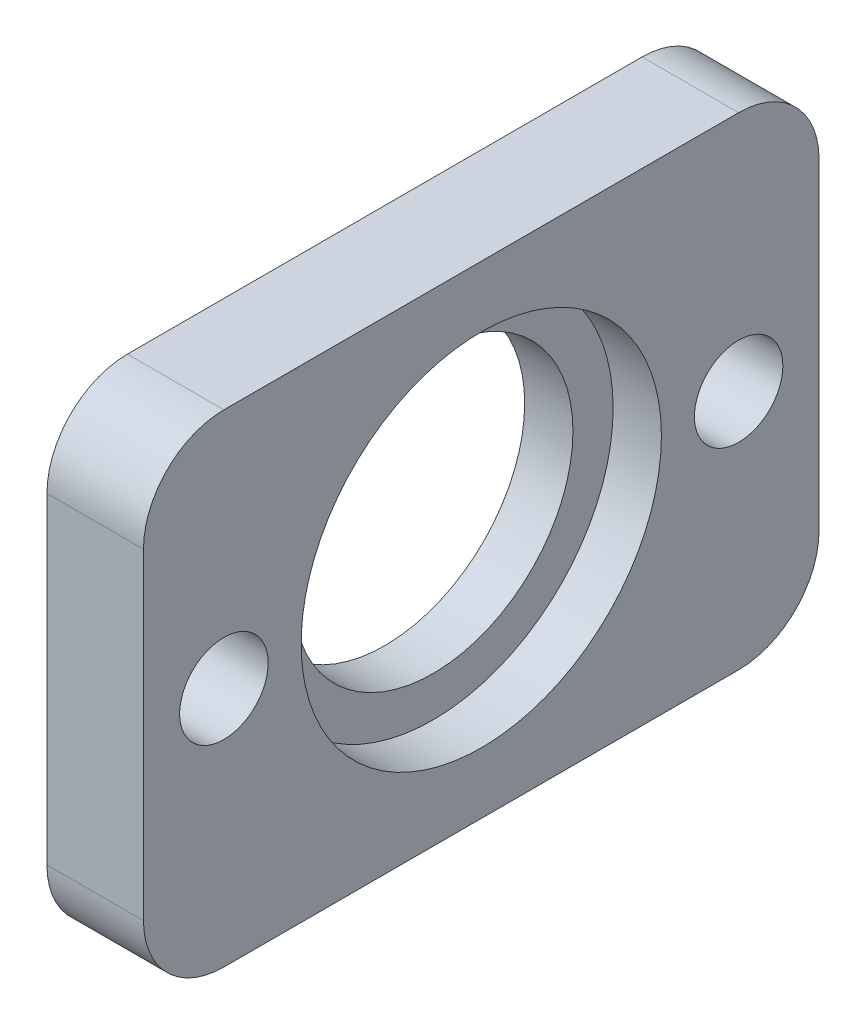
from build123d import *

# Parameters (mm, degrees)
SKIZZE1_W                        = 42
SKIZZE1_H                        = 30
AUFSATZ_LINEAR_AUSTRAGEN1_DEPTH  = 6
SKIZZE1_3_R                      = 8.7
SCHNITT_LINEAR_AUSTRAGEN1_DEPTH  = 6
SKIZZE1_4_R                      = 11.2
SCHNITT_LINEAR_AUSTRAGEN2_DEPTH  = 3
F_5_5_5_5_DURCHMESSER_BOHRUNG1_D = 5.5
VERRUNDUNG1_R                    = 5


with BuildPart() as part:
    # Skizze1 → Aufsatz-Linear austragen1 (new body)
    with BuildSketch(Plane(origin=(0, 0, 0), x_dir=(0, 0, -1), z_dir=(1, 0, 0))):
        Rectangle(SKIZZE1_W, SKIZZE1_H)
    extrude(amount=-AUFSATZ_LINEAR_AUSTRAGEN1_DEPTH)

    # Skizze1_3 → Schnitt-Linear austragen1 (cut)
    with BuildSketch(Plane(origin=(0, 0, 0), x_dir=(0, 0, -1), z_dir=(1, 0, 0))):
        Circle(SKIZZE1_3_R)
    extrude(amount=-SCHNITT_LINEAR_AUSTRAGEN1_DEPTH, mode=Mode.SUBTRACT)

    # Skizze1_4 → Schnitt-Linear austragen2 (cut)
    with BuildSketch(Plane(origin=(0, 0, 0), x_dir=(0, 0, -1), z_dir=(1, 0, 0))):
        Circle(SKIZZE1_4_R)
    extrude(amount=-SCHNITT_LINEAR_AUSTRAGEN2_DEPTH, mode=Mode.SUBTRACT)

    # Ø5.5 (5.5) Durchmesser Bohrung1 (through all)
    with Locations(Plane(origin=(0, 0, 0), x_dir=(0, 0, -1), z_dir=(1, 0, 0))):
        with Locations((-16, 0), (16, 0)):
            Hole(F_5_5_5_5_DURCHMESSER_BOHRUNG1_D / 2)

    # Verrundung1
    verrundung1_edges = [part.edges().sort_by_distance(p)[0] for p in [
        (-3, 15, 21),
        (-3, 15, -21),
        (-3, -15, -21),
        (-3, -15, 21),
    ]]
    fillet(verrundung1_edges, radius=VERRUNDUNG1_R)


solid = part.part
